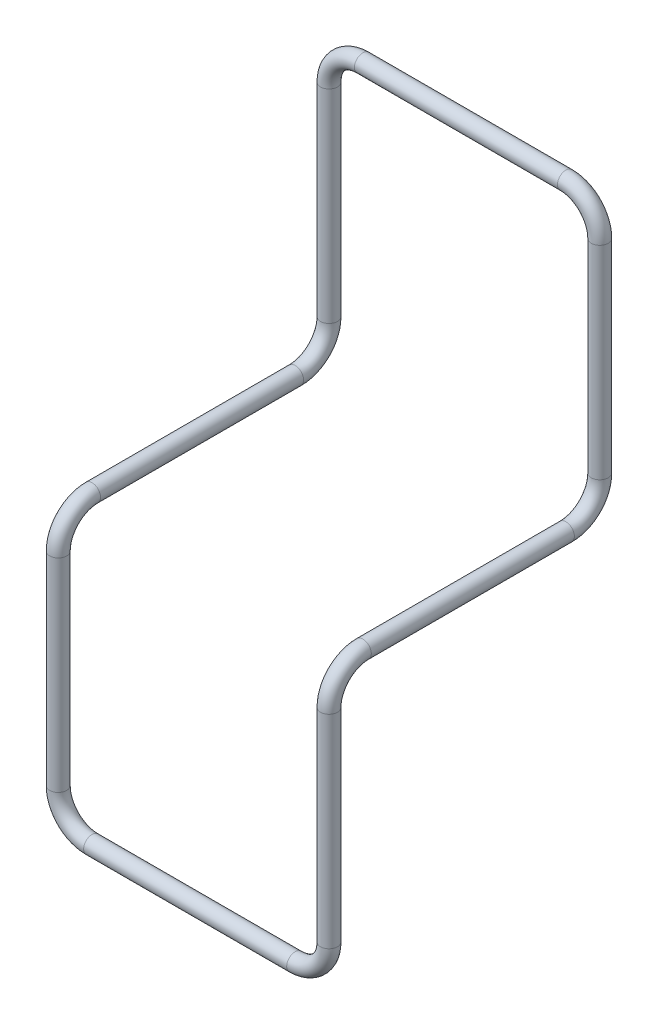
from build123d import *

# Parameters (mm, degrees)
SKETCH2_R = 1.5875


with BuildPart() as part:
    # Sweep1: sweep along a curve in space
    with BuildLine() as sweep1_path:
        Line((0, -6.35, 0), (0, -44.45, 0))
        ThreePointArc((0, -44.45, 0), (0, -48.940128061, 1.859871939), (0, -50.8, 6.35))
        Line((0, -50.8, 6.35), (0, -50.8, 44.45))
        ThreePointArc((0, -50.8, 44.45), (0, -52.659871939, 48.940128061), (0, -57.15, 50.8))
        Line((0, -57.15, 50.8), (0, -95.25, 50.8))
        ThreePointArc((0, -95.25, 50.8), (1.859871939, -99.740128061, 50.8), (6.35, -101.6, 50.8))
        Line((6.35, -101.6, 50.8), (44.45, -101.6, 50.8))
        ThreePointArc((44.45, -101.6, 50.8), (48.940128061, -99.740128061, 50.8), (50.8, -95.25, 50.8))
        Line((50.8, -95.25, 50.8), (50.8, -57.15, 50.8))
        ThreePointArc((50.8, -57.15, 50.8), (50.8, -52.659871939, 48.940128061), (50.8, -50.8, 44.45))
        Line((50.8, -50.8, 44.45), (50.8, -50.8, 6.35))
        ThreePointArc((50.8, -50.8, 6.35), (50.8, -48.940128061, 1.859871939), (50.8, -44.45, 0))
        Line((50.8, -44.45, 0), (50.8, -6.35, 0))
        ThreePointArc((50.8, -6.35, 0), (48.940128061, -1.859871939, 0), (44.45, 0, 0))
        Line((44.45, 0, 0), (6.35, 0, 0))
        ThreePointArc((0, -6.35, 0), (1.859871939, -1.859871939, 0), (6.35, 0, 0))
    # Sketch2 → Sweep1 (sweep)
    with BuildSketch(Plane(origin=(6.35, 0, 0), x_dir=(0, 0, -1), z_dir=(1, 0, 0))):
        Circle(SKETCH2_R)
    sweep(path=sweep1_path.line)


solid = part.part
